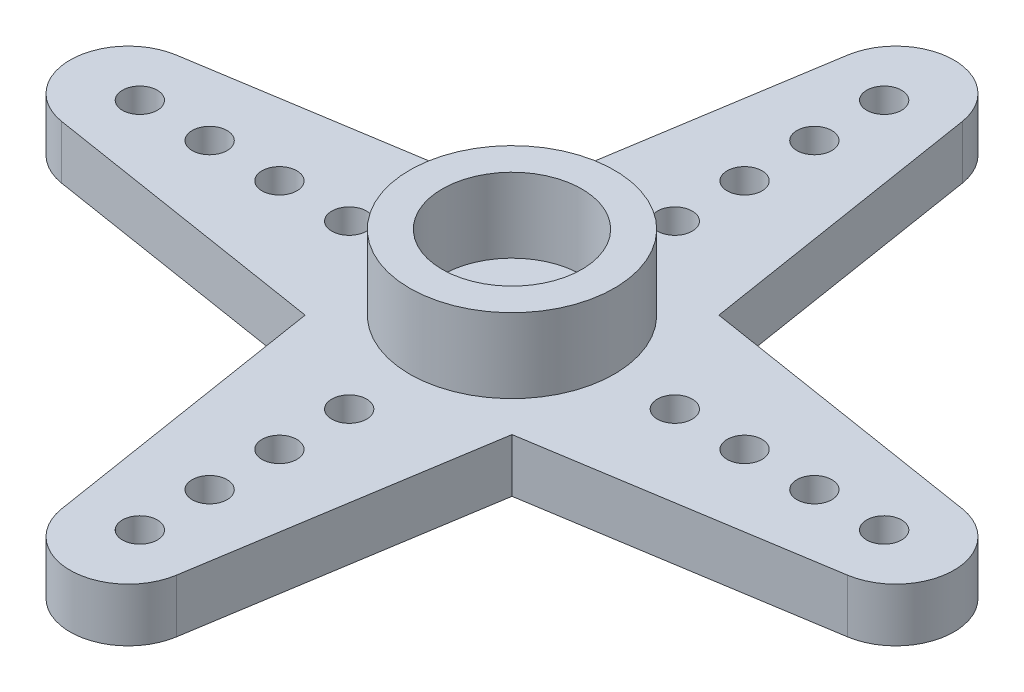
from build123d import *

# Parameters (mm, degrees)
SKETCH1_R           = 6.1
SKETCH1_R_2         = 1.5
BOSS_EXTRUDE1_DEPTH = 2.3
SKETCH2_R           = 4.4
SKETCH2_R_2         = 3
BOSS_EXTRUDE2_DEPTH = 3.2
SKETCH3_R           = 0.75
BOSS_EXTRUDE3_DEPTH = 2.3
CIRPATTERN1_COUNT   = 4


with BuildPart() as part:
    # Sketch1 → Boss-Extrude1 (new body)
    with BuildSketch(Plane(origin=(0, 0, 0), x_dir=(1, 0, 0), z_dir=(0, 1, 0))):
        Circle(SKETCH1_R)
        Circle(SKETCH1_R_2, mode=Mode.SUBTRACT)
    extrude(amount=BOSS_EXTRUDE1_DEPTH)

    # Sketch2 → Boss-Extrude2 (add)
    with BuildSketch(Plane(origin=(0, 2.3, 0), x_dir=(1, 0, 0), z_dir=(0, 1, 0))):
        Circle(SKETCH2_R)
        Circle(SKETCH2_R_2, mode=Mode.SUBTRACT)
    extrude(amount=BOSS_EXTRUDE2_DEPTH)

    # Sketch3 → Boss-Extrude3 (add)
    with BuildSketch(Plane.XZ):
        with BuildLine():
            Line((-4.5, -4.118252056), (-2.468988638, -16.892549493))
            ThreePointArc((-2.468988638, -16.892549493), (0, -19), (2.468988638, -16.892549493))
            Line((2.468988638, -16.892549493), (4.5, -4.118252056))
            ThreePointArc((4.5, -4.118252056), (0, -6.1), (-4.5, -4.118252056))
        make_face()
        with Locations((0, -16)):
            Circle(SKETCH3_R, mode=Mode.SUBTRACT)
        with Locations((0, -13)):
            Circle(SKETCH3_R, mode=Mode.SUBTRACT)
        with Locations((0, -10)):
            Circle(SKETCH3_R, mode=Mode.SUBTRACT)
        with Locations((0, -7)):
            Circle(SKETCH3_R, mode=Mode.SUBTRACT)
    boss_extrude3 = extrude(amount=-BOSS_EXTRUDE3_DEPTH)

    # CirPattern1: Boss-Extrude3 ×4 about axis
    cirpattern1_axis = Axis((0, 0, 0), (0, 1, 0))
    for i in range(1, CIRPATTERN1_COUNT):
        add(boss_extrude3.rotate(cirpattern1_axis, i * 360 / CIRPATTERN1_COUNT))


solid = part.part
